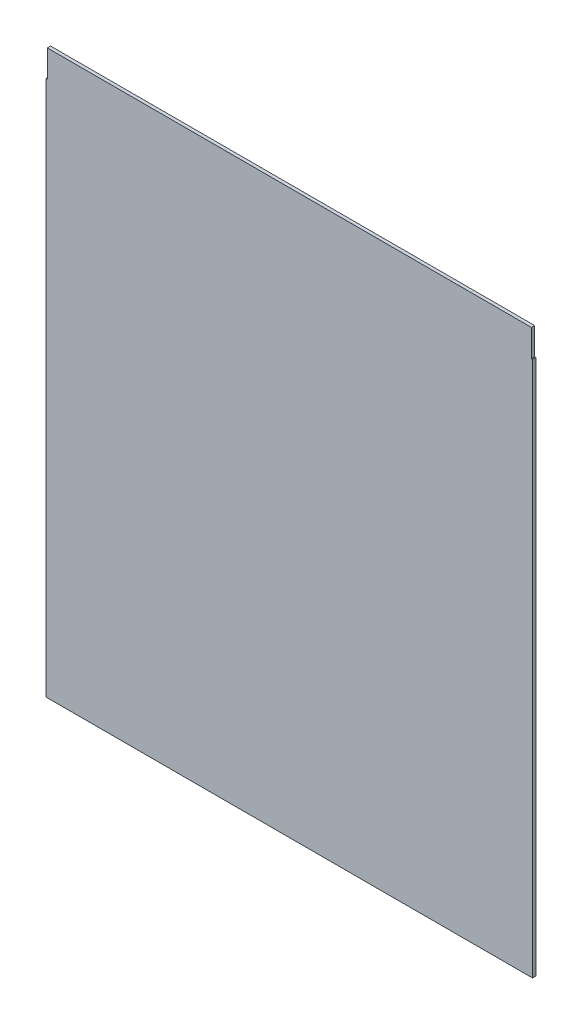
from build123d import *

# Parameters (mm, degrees)
SALIENTE_EXTRUIR1_DEPTH = 3


with BuildPart() as part:
    # Croquis1 → Saliente-Extruir1 (new body)
    with BuildSketch(Plane.XY):
        Polygon((-261.838674033, 298.703267526), (-260.838674033, 298.703267526), (-260.838674033, 323.703267526), (187.161325967, 323.703267526), (187.161325967, 298.703267526), (188.161325967, 298.703267526), (188.161325967, -197.096732474), (-261.838674033, -197.096732474), align=None)
    extrude(amount=SALIENTE_EXTRUIR1_DEPTH)


solid = part.part
